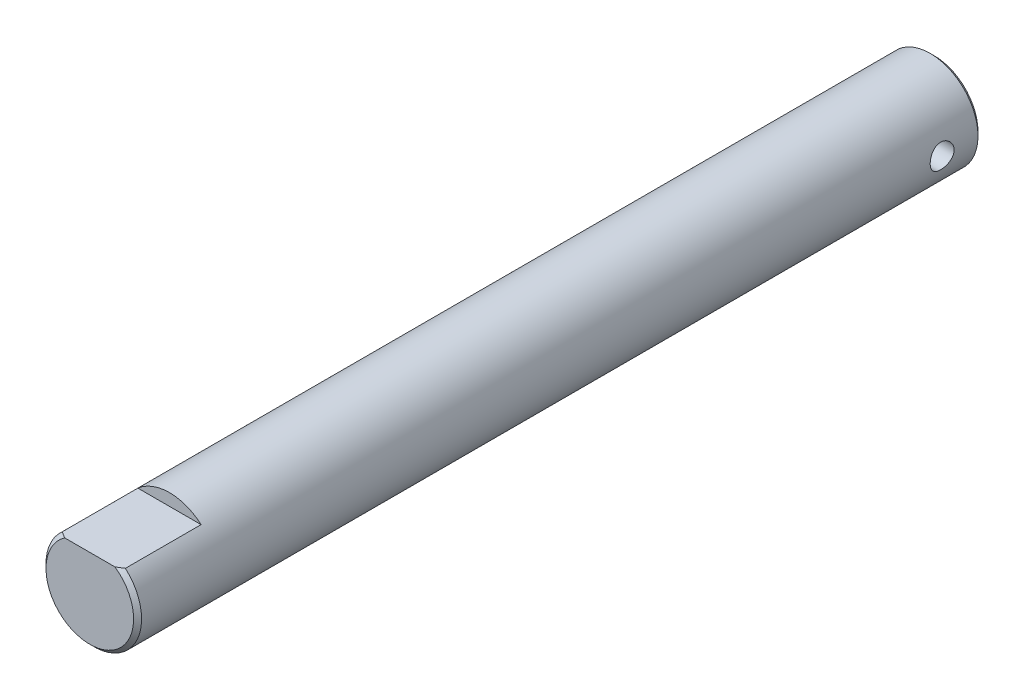
from build123d import *

# Parameters (mm, degrees)
SKETCH1_R               = 6
BOSS_EXTRUDE1_DEPTH     = 106
CHAMFER1_SIZE           = 0.5
SKETCH2_W               = 20
SKETCH2_H               = 5
CUT_EXTRUDE1_DEPTH      = 10
SKETCH3_R               = 1.5
CUT_EXTRUDE2_DEPTH      = 7
CUT_EXTRUDE2_DEPTH_BACK = 7


with BuildPart() as part:
    # Sketch1 → Boss-Extrude1 (new body)
    with BuildSketch(Plane.XY):
        Circle(SKETCH1_R)
    extrude(amount=BOSS_EXTRUDE1_DEPTH)

    # Chamfer1
    chamfer1_edges = [part.edges().sort_by_distance(p)[0] for p in [
        (-6, 0, 0),
        (-6, 0, 106),
    ]]
    chamfer(chamfer1_edges, length=CHAMFER1_SIZE)

    # Sketch2 → Cut-Extrude1 (cut)
    with BuildSketch(Plane.XY.offset(106)):
        with Locations((0, 7)):
            Rectangle(SKETCH2_W, SKETCH2_H)
    extrude(amount=-CUT_EXTRUDE1_DEPTH, mode=Mode.SUBTRACT)

    # Sketch3 → Cut-Extrude2 (cut, two sides)
    with BuildSketch(Plane(origin=(0, 0, 0), x_dir=(0, 0, -1), z_dir=(1, 0, 0))) as cut_extrude2_sk:
        with Locations((-5, 0)):
            Circle(SKETCH3_R)
    extrude(amount=CUT_EXTRUDE2_DEPTH, mode=Mode.SUBTRACT)
    extrude(cut_extrude2_sk.sketch, amount=-CUT_EXTRUDE2_DEPTH_BACK, mode=Mode.SUBTRACT)


solid = part.part
